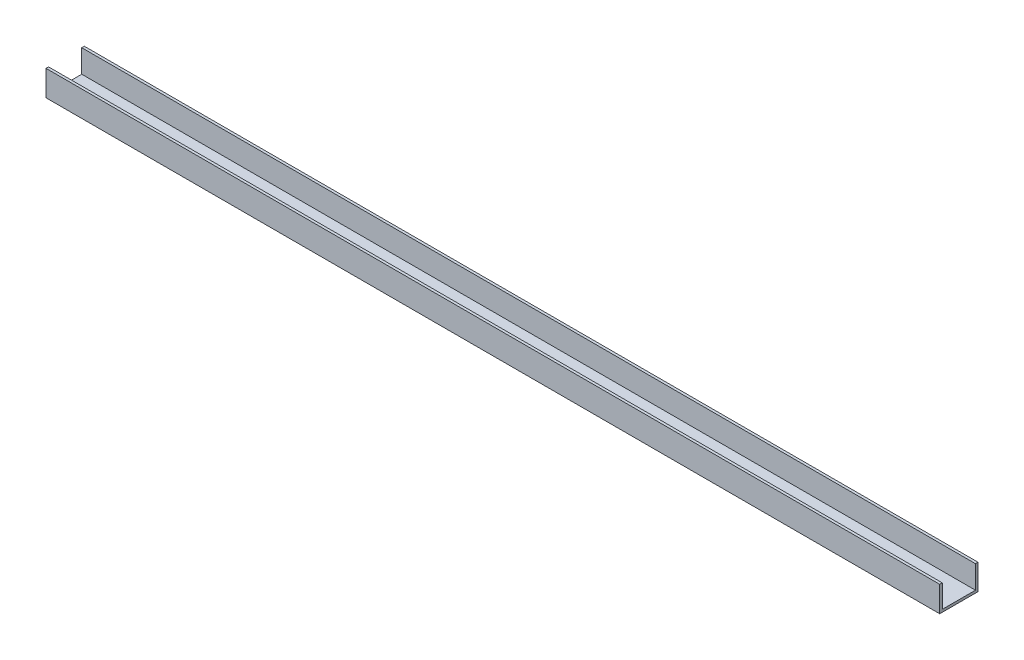
from build123d import *

# Parameters (mm, degrees)
SKETCH2_W           = 350
SKETCH2_H           = 15
BOSS_EXTRUDE1_DEPTH = 10
SKETCH3_W           = 350
SKETCH3_H           = 13
CUT_EXTRUDE1_DEPTH  = 9
SKETCH4_R           = 2.4
SKETCH4_R_2         = 2.5
CUT_EXTRUDE3_DEPTH  = 10


with BuildPart() as part:
    # Sketch2 → Boss-Extrude1 (new body)
    with BuildSketch(Plane(origin=(0, 0, 0), x_dir=(1, 0, 0), z_dir=(0, 1, 0))):
        with Locations((214.483557787, 122.439976597)):
            Rectangle(SKETCH2_W, SKETCH2_H)
    extrude(amount=BOSS_EXTRUDE1_DEPTH)

    # Sketch3 → Cut-Extrude1 (cut)
    with BuildSketch(Plane(origin=(0, 10, 0), x_dir=(1, 0, 0), z_dir=(0, 1, 0))):
        with Locations((214.483557787, 122.439976597)):
            Rectangle(SKETCH3_W, SKETCH3_H)
    extrude(amount=-CUT_EXTRUDE1_DEPTH, mode=Mode.SUBTRACT)

    # Sketch4 → Cut-Extrude3 (cut)
    with BuildSketch(Plane(origin=(0, 1, 0), x_dir=(1, 0, 0), z_dir=(0, 1, 0))):
        with Locations((59.483557787, 122.439976597)):
            Circle(SKETCH4_R)
        with Locations((359.483557787, 122.439976597)):
            Circle(SKETCH4_R_2)
    extrude(amount=-CUT_EXTRUDE3_DEPTH, mode=Mode.SUBTRACT)


solid = part.part
